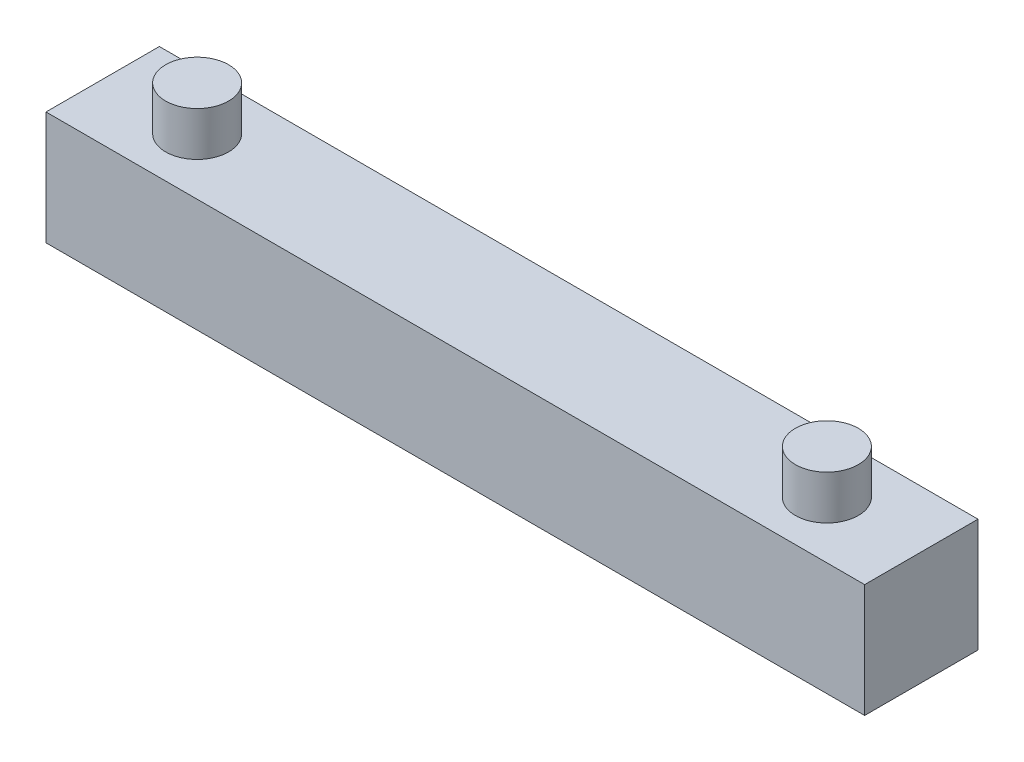
from build123d import *

# Parameters (mm, degrees)
SKETCH3_W           = 65
SKETCH3_H           = 9
BOSS_EXTRUDE2_DEPTH = 9
SKETCH4_R           = 2.5
BOSS_EXTRUDE3_DEPTH = 3.5


with BuildPart() as part:
    # Sketch3 → Boss-Extrude2 (new body)
    with BuildSketch(Plane.XY):
        with Locations((32.5, 4.5)):
            Rectangle(SKETCH3_W, SKETCH3_H)
    extrude(amount=BOSS_EXTRUDE2_DEPTH)

    # Sketch4 → Boss-Extrude3 (add)
    with BuildSketch(Plane(origin=(0, 9, 0), x_dir=(1, 0, 0), z_dir=(0, 1, 0))):
        with Locations(Location((57.5, -4.5, 0), (0, 0, 90))):  # turned: the seam where the file's is
            Circle(SKETCH4_R)
        with Locations(Location((7.5, -4.5, 0), (0, 0, 90))):  # turned: the seam where the file's is
            Circle(SKETCH4_R)
    extrude(amount=BOSS_EXTRUDE3_DEPTH)


solid = part.part
